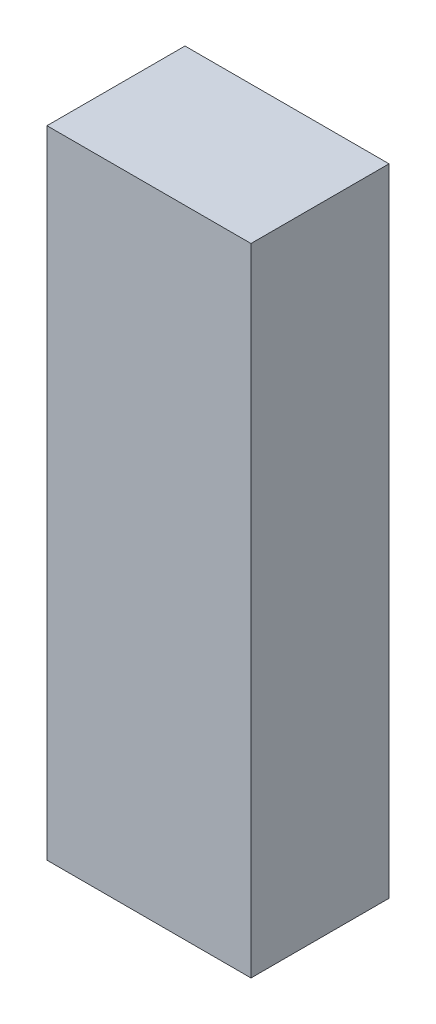
from build123d import *

# Parameters (mm, degrees)
SKETCH1_W           = 34
SKETCH1_H           = 106
BOSS_EXTRUDE1_DEPTH = 23


with BuildPart() as part:
    # Sketch1 → Boss-Extrude1 (new body)
    with BuildSketch(Plane.XY):
        with Locations((17, 53)):
            Rectangle(SKETCH1_W, SKETCH1_H)
    extrude(amount=BOSS_EXTRUDE1_DEPTH)


solid = part.part
